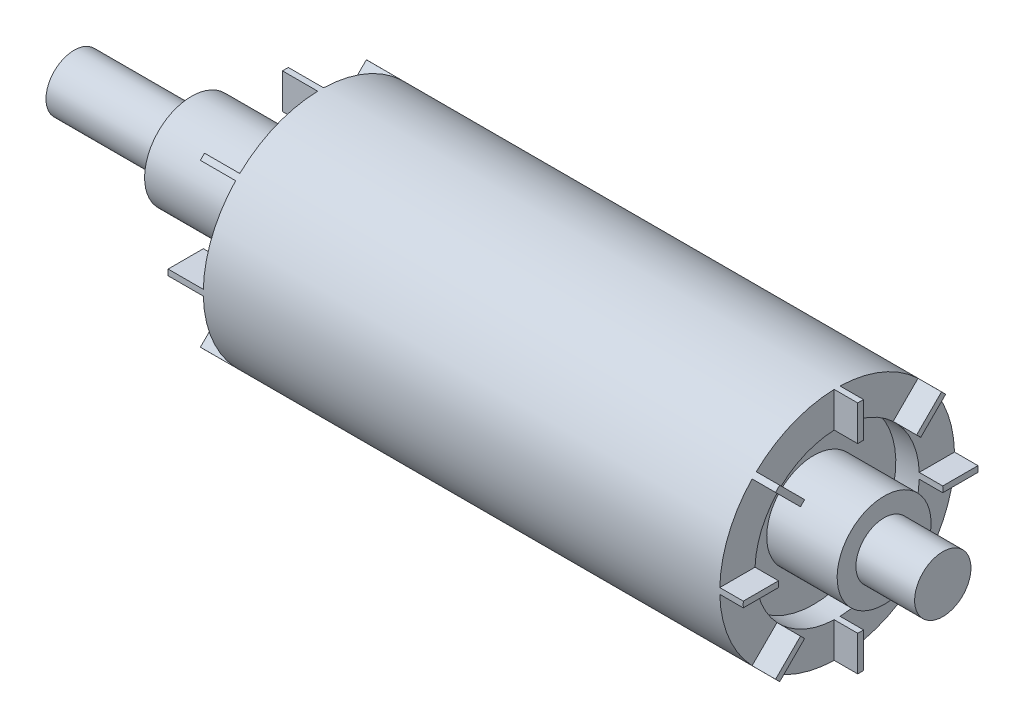
from build123d import *
from build123d.topology import SkipClean

# Parameters (mm, degrees)
BOSS_EXTRUDE1_DEPTH = 15
BOSS_EXTRUDE2_START = -220
BOSS_EXTRUDE2_DEPTH = 10


with BuildPart() as part:
    # Sketch1 → Revolve2 (revolve)
    with BuildSketch(Plane.XY, mode=Mode.PRIVATE) as revolve2_sk:
        Polygon((-185, 0), (-185, 12), (-135, 12), (-135, 20), (-70, 20), (-70, 35), (-80, 35), (-80, 50), (140, 50), (140, 35), (130, 35), (130, 20), (160, 20), (160, 12), (185, 12), (185, 0), align=None)
    revolve(revolve2_sk.sketch.rotate(Axis((-185, 0, 0), (1, 0, 0)), 180), axis=Axis((-185, 0, 0), (1, 0, 0)))

    # Sketch4 → Boss-Extrude1 (add)
    with SkipClean():  # the faces are left unmerged after this step: merging them gives an invalid solid
        with BuildSketch(Plane.ZY.offset(80)):
            with BuildLine():
                Line((-1.25, 49.984372558), (-1.25, 34.977671449))
                ThreePointArc((-1.25, 34.977671449), (0, 35), (1.25, 34.977671449))
                Line((1.25, 34.977671449), (1.25, 49.984372558))
                ThreePointArc((1.25, 49.984372558), (0, 50), (-1.25, 49.984372558))
            make_face()
            with BuildLine():
                Line((34.460405313, 36.228172265), (23.849065195, 25.616832148))
                ThreePointArc((23.849065195, 25.616832148), (24.748737342, 24.748737342), (25.616832148, 23.849065195))
                Line((25.616832148, 23.849065195), (36.228172265, 34.460405313))
                ThreePointArc((36.228172265, 34.460405313), (35.355339059, 35.355339059), (34.460405313, 36.228172265))
            make_face()
            with BuildLine():
                Line((49.984372558, 1.25), (34.977671449, 1.25))
                ThreePointArc((34.977671449, 1.25), (35, 0), (34.977671449, -1.25))
                Line((34.977671449, -1.25), (49.984372558, -1.25))
                ThreePointArc((49.984372558, -1.25), (50, 0), (49.984372558, 1.25))
            make_face()
            with BuildLine():
                Line((36.228172265, -34.460405313), (25.616832148, -23.849065195))
                ThreePointArc((25.616832148, -23.849065195), (24.748737342, -24.748737342), (23.849065195, -25.616832148))
                Line((23.849065195, -25.616832148), (34.460405313, -36.228172265))
                ThreePointArc((34.460405313, -36.228172265), (35.355339059, -35.355339059), (36.228172265, -34.460405313))
            make_face()
            with BuildLine():
                Line((1.25, -49.984372558), (1.25, -34.977671449))
                ThreePointArc((1.25, -34.977671449), (0, -35), (-1.25, -34.977671449))
                Line((-1.25, -34.977671449), (-1.25, -49.984372558))
                ThreePointArc((-1.25, -49.984372558), (0, -50), (1.25, -49.984372558))
            make_face()
            with BuildLine():
                Line((-34.460405313, -36.228172265), (-23.849065195, -25.616832148))
                ThreePointArc((-23.849065195, -25.616832148), (-24.748737342, -24.748737342), (-25.616832148, -23.849065195))
                Line((-25.616832148, -23.849065195), (-36.228172265, -34.460405313))
                ThreePointArc((-36.228172265, -34.460405313), (-35.355339059, -35.355339059), (-34.460405313, -36.228172265))
            make_face()
            with BuildLine():
                Line((-49.984372558, -1.25), (-34.977671449, -1.25))
                ThreePointArc((-34.977671449, -1.25), (-35, 0), (-34.977671449, 1.25))
                Line((-34.977671449, 1.25), (-49.984372558, 1.25))
                ThreePointArc((-49.984372558, 1.25), (-50, 0), (-49.984372558, -1.25))
            make_face()
            with BuildLine():
                Line((-36.228172265, 34.460405313), (-25.616832148, 23.849065195))
                ThreePointArc((-25.616832148, 23.849065195), (-24.748737342, 24.748737342), (-23.849065195, 25.616832148))
                Line((-23.849065195, 25.616832148), (-34.460405313, 36.228172265))
                ThreePointArc((-34.460405313, 36.228172265), (-35.355339059, 35.355339059), (-36.228172265, 34.460405313))
            make_face()
        extrude(amount=BOSS_EXTRUDE1_DEPTH)

    # Sketch4_2 → Boss-Extrude2 (add)
    with SkipClean():  # the faces are left unmerged after this step: merging them gives an invalid solid
        with BuildSketch(Plane.ZY.offset(80).offset(BOSS_EXTRUDE2_START)):
            with BuildLine():
                ThreePointArc((1.25, 49.984372558), (0, 50), (-1.25, 49.984372558))
                Line((-1.25, 49.984372558), (-1.25, 34.977671449))
                ThreePointArc((-1.25, 34.977671449), (0, 35), (1.25, 34.977671449))
                Line((1.25, 34.977671449), (1.25, 49.984372558))
            make_face()
            with BuildLine():
                Line((-23.849065195, 25.616832148), (-34.460405313, 36.228172265))
                ThreePointArc((-34.460405313, 36.228172265), (-35.355339059, 35.355339059), (-36.228172265, 34.460405313))
                Line((-36.228172265, 34.460405313), (-25.616832148, 23.849065195))
                ThreePointArc((-25.616832148, 23.849065195), (-24.748737342, 24.748737342), (-23.849065195, 25.616832148))
            make_face()
            with BuildLine():
                ThreePointArc((36.228172265, 34.460405313), (35.355339059, 35.355339059), (34.460405313, 36.228172265))
                Line((34.460405313, 36.228172265), (23.849065195, 25.616832148))
                ThreePointArc((23.849065195, 25.616832148), (24.748737342, 24.748737342), (25.616832148, 23.849065195))
                Line((25.616832148, 23.849065195), (36.228172265, 34.460405313))
            make_face()
            with BuildLine():
                Line((-34.977671449, 1.25), (-49.984372558, 1.25))
                ThreePointArc((-49.984372558, 1.25), (-50, 0), (-49.984372558, -1.25))
                Line((-49.984372558, -1.25), (-34.977671449, -1.25))
                ThreePointArc((-34.977671449, -1.25), (-35, 0), (-34.977671449, 1.25))
            make_face()
            with BuildLine():
                ThreePointArc((49.984372558, -1.25), (50, 0), (49.984372558, 1.25))
                Line((49.984372558, 1.25), (34.977671449, 1.25))
                ThreePointArc((34.977671449, 1.25), (35, 0), (34.977671449, -1.25))
                Line((34.977671449, -1.25), (49.984372558, -1.25))
            make_face()
            with BuildLine():
                Line((-25.616832148, -23.849065195), (-36.228172265, -34.460405313))
                ThreePointArc((-36.228172265, -34.460405313), (-35.355339059, -35.355339059), (-34.460405313, -36.228172265))
                Line((-34.460405313, -36.228172265), (-23.849065195, -25.616832148))
                ThreePointArc((-23.849065195, -25.616832148), (-24.748737342, -24.748737342), (-25.616832148, -23.849065195))
            make_face()
            with BuildLine():
                ThreePointArc((34.460405313, -36.228172265), (35.355339059, -35.355339059), (36.228172265, -34.460405313))
                Line((36.228172265, -34.460405313), (25.616832148, -23.849065195))
                ThreePointArc((25.616832148, -23.849065195), (24.748737342, -24.748737342), (23.849065195, -25.616832148))
                Line((23.849065195, -25.616832148), (34.460405313, -36.228172265))
            make_face()
            with BuildLine():
                Line((-1.25, -34.977671449), (-1.25, -49.984372558))
                ThreePointArc((-1.25, -49.984372558), (0, -50), (1.25, -49.984372558))
                Line((1.25, -49.984372558), (1.25, -34.977671449))
                ThreePointArc((1.25, -34.977671449), (0, -35), (-1.25, -34.977671449))
            make_face()
        extrude(amount=-BOSS_EXTRUDE2_DEPTH)


solid = part.part
